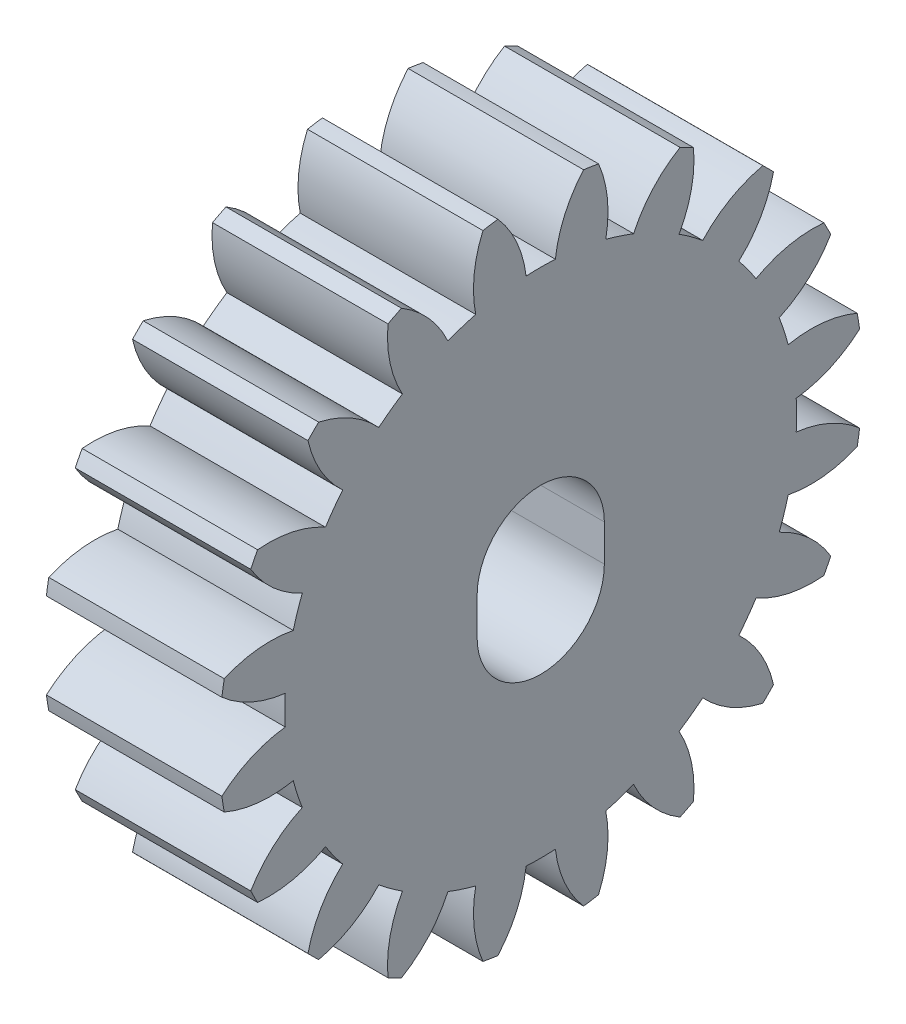
from build123d import *

# Parameters (mm, degrees)
EXTRUDE_1_DEPTH = 6


with BuildPart() as part:
    # Эскиз1 → Бобышка-Вытянуть1 (new body)
    with BuildSketch(Plane(origin=(0.204923016, 3.152126199, 1.20502958), x_dir=(0, 0, -1), z_dir=(1, 0, 0))):
        with BuildLine():
            ThreePointArc((-9.696984117, -1.687169764), (-8.686522764, -2.334065374), (-7.529675738, -2.652202191))
            ThreePointArc((-7.529675738, -2.652202191), (-7.54397042, -3.152126199), (-7.529675738, -3.652050206))
            ThreePointArc((-7.529675738, -3.652050206), (-8.686522764, -3.970187024), (-9.696984117, -4.617082634))
            ThreePointArc((-9.696984117, -4.617082634), (-9.659542166, -4.872905314), (-9.616098021, -5.12777734))
            ThreePointArc((-9.616098021, -5.12777734), (-8.45519043, -5.430761896), (-7.256653844, -5.375842598))
            ThreePointArc((-7.256653844, -5.375842598), (-7.115763881, -5.855715883), (-6.947683816, -6.326754568))
            ThreePointArc((-6.947683816, -6.326754568), (-7.949601035, -6.986806052), (-8.710705152, -7.914290068))
            ThreePointArc((-8.710705152, -7.914290068), (-8.596042186, -8.146021696), (-8.475964561, -8.374994418))
            ThreePointArc((-8.475964561, -8.374994418), (-7.278248455, -8.304409679), (-6.155343422, -7.88181015))
            ThreePointArc((-6.155343422, -7.88181015), (-5.873060104, -8.294659371), (-5.567647504, -8.690704186))
            ThreePointArc((-5.567647504, -8.690704186), (-6.316560278, -9.628059899), (-6.753804986, -10.745343722))
            ThreePointArc((-6.753804986, -10.745343722), (-6.573145013, -10.930300792), (-6.388187943, -11.110960765))
            ThreePointArc((-6.388187943, -11.110960765), (-5.27090412, -10.673716057), (-4.333548407, -9.924803283))
            ThreePointArc((-4.333548407, -9.924803283), (-3.937503592, -10.230215883), (-3.524654371, -10.512499201))
            ThreePointArc((-3.524654371, -10.512499201), (-3.9472539, -11.635404234), (-4.017838639, -12.83312034))
            ThreePointArc((-4.017838639, -12.83312034), (-3.788865917, -12.953197965), (-3.557134289, -13.067860931))
            ThreePointArc((-3.557134289, -13.067860931), (-2.629650273, -12.306756814), (-1.969598789, -11.304839595))
            ThreePointArc((-1.969598789, -11.304839595), (-1.498560104, -11.47291966), (-1.018686819, -11.613809623))
            ThreePointArc((-1.018686819, -11.613809623), (-1.073606117, -12.812346209), (-0.770621561, -13.9732538))
            ThreePointArc((-0.770621561, -13.9732538), (-0.515749535, -14.016697945), (-0.259926855, -14.054139896))
            ThreePointArc((-0.259926855, -14.054139896), (0.386968755, -13.043678543), (0.705105573, -11.886831517))
            ThreePointArc((0.705105573, -11.886831517), (1.20502958, -11.901126199), (1.704953588, -11.886831517))
            ThreePointArc((1.704953588, -11.886831517), (2.023090405, -13.043678543), (2.669986015, -14.054139896))
            ThreePointArc((2.669986015, -14.054139896), (2.925808695, -14.016697945), (3.180680722, -13.9732538))
            ThreePointArc((3.180680722, -13.9732538), (3.483665277, -12.812346209), (3.428745979, -11.613809623))
            ThreePointArc((3.428745979, -11.613809623), (3.908619264, -11.47291966), (4.379657949, -11.304839595))
            ThreePointArc((4.379657949, -11.304839595), (5.039709433, -12.306756814), (5.967193449, -13.067860931))
            ThreePointArc((5.967193449, -13.067860931), (6.198925077, -12.953197965), (6.427897799, -12.83312034))
            ThreePointArc((6.427897799, -12.83312034), (6.35731306, -11.635404234), (5.934713531, -10.512499201))
            ThreePointArc((5.934713531, -10.512499201), (6.347562752, -10.230215883), (6.743607567, -9.924803283))
            ThreePointArc((6.743607567, -9.924803283), (7.68096328, -10.673716057), (8.798247103, -11.110960765))
            ThreePointArc((8.798247103, -11.110960765), (8.983204173, -10.930300792), (9.163864146, -10.745343722))
            ThreePointArc((9.163864146, -10.745343722), (8.726619438, -9.628059899), (7.977706664, -8.690704186))
            ThreePointArc((7.977706664, -8.690704186), (8.283119264, -8.294659371), (8.565402582, -7.88181015))
            ThreePointArc((8.565402582, -7.88181015), (9.688307615, -8.304409679), (10.886023721, -8.374994418))
            ThreePointArc((10.886023721, -8.374994418), (11.006101346, -8.146021696), (11.120764313, -7.914290068))
            ThreePointArc((11.120764313, -7.914290068), (10.359660195, -6.986806052), (9.357742976, -6.326754568))
            ThreePointArc((9.357742976, -6.326754568), (9.525823041, -5.855715883), (9.666713005, -5.375842598))
            ThreePointArc((9.666713005, -5.375842598), (10.86524959, -5.430761896), (12.026157182, -5.12777734))
            ThreePointArc((12.026157182, -5.12777734), (12.069601327, -4.872905314), (12.107043277, -4.617082634))
            ThreePointArc((12.107043277, -4.617082634), (11.096581924, -3.970187024), (9.939734898, -3.652050206))
            ThreePointArc((9.939734898, -3.652050206), (9.95402958, -3.152126199), (9.939734898, -2.652202191))
            ThreePointArc((9.939734898, -2.652202191), (11.096581924, -2.334065374), (12.107043277, -1.687169764))
            ThreePointArc((12.107043277, -1.687169764), (12.069601327, -1.431347083), (12.026157182, -1.176475057))
            ThreePointArc((12.026157182, -1.176475057), (10.86524959, -0.873490502), (9.666713005, -0.9284098))
            ThreePointArc((9.666713005, -0.9284098), (9.525823041, -0.448536515), (9.357742976, 0.02250217))
            ThreePointArc((9.357742976, 0.02250217), (10.359660195, 0.682553654), (11.120764313, 1.61003767))
            ThreePointArc((11.120764313, 1.61003767), (11.006101346, 1.841769298), (10.886023721, 2.07074202))
            ThreePointArc((10.886023721, 2.07074202), (9.688307615, 2.000157281), (8.565402582, 1.577557752))
            ThreePointArc((8.565402582, 1.577557752), (8.283119264, 1.990406973), (7.977706664, 2.386451788))
            ThreePointArc((7.977706664, 2.386451788), (8.726619438, 3.323807501), (9.163864146, 4.441091324))
            ThreePointArc((9.163864146, 4.441091324), (8.983204173, 4.626048394), (8.798247103, 4.806708367))
            ThreePointArc((8.798247103, 4.806708367), (7.68096328, 4.369463659), (6.743607567, 3.620550885))
            ThreePointArc((6.743607567, 3.620550885), (6.347562752, 3.925963485), (5.934713531, 4.208246803))
            ThreePointArc((5.934713531, 4.208246803), (6.35731306, 5.331151836), (6.427897799, 6.528867942))
            ThreePointArc((6.427897799, 6.528867942), (6.198925077, 6.648945567), (5.967193449, 6.763608534))
            ThreePointArc((5.967193449, 6.763608534), (5.039709433, 6.002504416), (4.379657949, 5.000587197))
            ThreePointArc((4.379657949, 5.000587197), (3.908619264, 5.168667262), (3.428745979, 5.309557226))
            ThreePointArc((3.428745979, 5.309557226), (3.483665277, 6.508093811), (3.180680722, 7.669001403))
            ThreePointArc((3.180680722, 7.669001403), (2.925808695, 7.712445548), (2.669986015, 7.749887498))
            ThreePointArc((2.669986015, 7.749887498), (2.023090405, 6.739426145), (1.704953588, 5.582579119))
            ThreePointArc((1.704953588, 5.582579119), (1.20502958, 5.596873801), (0.705105573, 5.582579119))
            ThreePointArc((0.705105573, 5.582579119), (0.386968755, 6.739426145), (-0.259926855, 7.749887498))
            ThreePointArc((-0.259926855, 7.749887498), (-0.515749535, 7.712445548), (-0.770621561, 7.669001403))
            ThreePointArc((-0.770621561, 7.669001403), (-1.073606117, 6.508093811), (-1.018686819, 5.309557226))
            ThreePointArc((-1.018686819, 5.309557226), (-1.498560104, 5.168667262), (-1.969598789, 5.000587197))
            ThreePointArc((-1.969598789, 5.000587197), (-2.629650273, 6.002504416), (-3.557134289, 6.763608534))
            ThreePointArc((-3.557134289, 6.763608534), (-3.788865917, 6.648945567), (-4.017838639, 6.528867942))
            ThreePointArc((-4.017838639, 6.528867942), (-3.9472539, 5.331151836), (-3.524654371, 4.208246803))
            ThreePointArc((-3.524654371, 4.208246803), (-3.937503592, 3.925963485), (-4.333548407, 3.620550885))
            ThreePointArc((-4.333548407, 3.620550885), (-5.27090412, 4.369463659), (-6.388187943, 4.806708367))
            ThreePointArc((-6.388187943, 4.806708367), (-6.573145013, 4.626048394), (-6.753804986, 4.441091324))
            ThreePointArc((-6.753804986, 4.441091324), (-6.316560278, 3.323807501), (-5.567647504, 2.386451788))
            ThreePointArc((-5.567647504, 2.386451788), (-5.873060104, 1.990406973), (-6.155343422, 1.577557752))
            ThreePointArc((-6.155343422, 1.577557752), (-7.278248455, 2.000157281), (-8.475964561, 2.07074202))
            ThreePointArc((-8.475964561, 2.07074202), (-8.596042186, 1.841769298), (-8.710705152, 1.61003767))
            ThreePointArc((-8.710705152, 1.61003767), (-7.949601035, 0.682553654), (-6.947683816, 0.02250217))
            ThreePointArc((-6.947683816, 0.02250217), (-7.115763881, -0.448536515), (-7.256653844, -0.9284098))
            ThreePointArc((-7.256653844, -0.9284098), (-8.45519043, -0.873490502), (-9.616098021, -1.176475057))
            ThreePointArc((-9.616098021, -1.176475057), (-9.659542166, -1.431347083), (-9.696984117, -1.687169764))
        make_face()
        with BuildLine():
            Line((3.38002958, -3.033706418), (3.38002958, -4.283706418))
            ThreePointArc((3.38002958, -4.283706418), (1.20502958, -6.458706418), (-0.96997042, -4.283706418))
            Line((-0.96997042, -4.283706418), (-0.96997042, -3.033706418))
            ThreePointArc((-0.96997042, -3.033706418), (1.20502958, -0.858706418), (3.38002958, -3.033706418))
        make_face(mode=Mode.SUBTRACT)
    extrude(amount=-EXTRUDE_1_DEPTH)


solid = part.part
